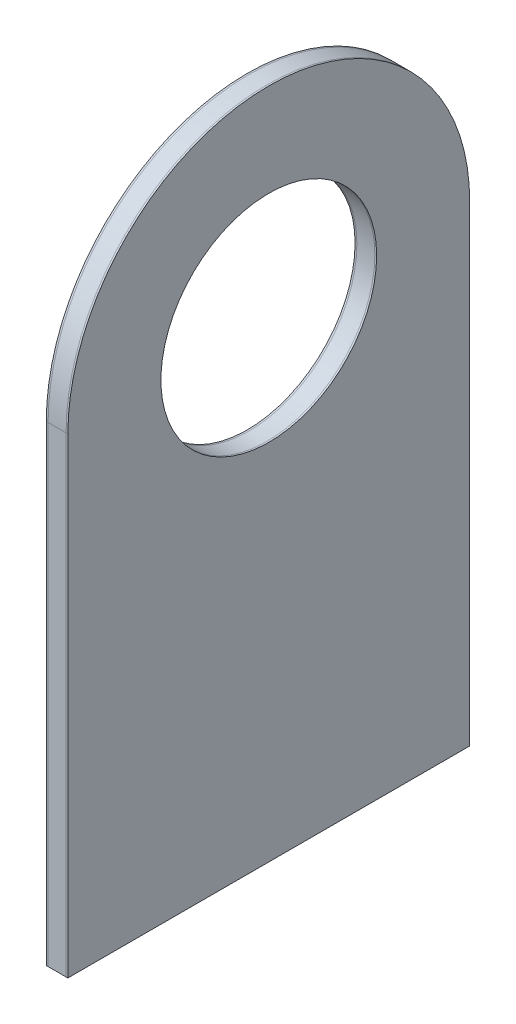
from build123d import *

# Parameters (mm, degrees)
SKETCH1_R           = 15
BOSS_EXTRUDE1_DEPTH = 0.25
SKETCH2_R           = 15
BOSS_EXTRUDE2_DEPTH = 2.5
SKETCH3_R           = 15
BOSS_EXTRUDE3_DEPTH = 0.25


with BuildPart() as part:
    # Sketch1 → Boss-Extrude1 (new body)
    with BuildSketch(Plane(origin=(0, 0, 0), x_dir=(0, 0, -1), z_dir=(1, 0, 0))):
        with BuildLine():
            Line((-27.94, 65.532), (-27.94, 0))
            Line((-27.94, 0), (27.94, 0))
            Line((27.94, 0), (27.94, 65.532))
            ThreePointArc((27.94, 65.532), (0, 93.472), (-27.94, 65.532))
        make_face()
        with Locations((0, 65.532)):
            Circle(SKETCH1_R, mode=Mode.SUBTRACT)
    extrude(amount=BOSS_EXTRUDE1_DEPTH)


with BuildPart() as body_2:
    # Sketch2 → Boss-Extrude2 (new body)
    with BuildSketch(Plane(origin=(0.25, 0, 0), x_dir=(0, 0, -1), z_dir=(1, 0, 0))):
        with BuildLine():
            Line((27.94, 0), (27.94, 65.532))
            ThreePointArc((27.94, 65.532), (0, 93.472), (-27.94, 65.532))
            Line((-27.94, 65.532), (-27.94, 0))
            Line((-27.94, 0), (27.94, 0))
        make_face()
        with Locations((0, 65.532)):
            Circle(SKETCH2_R, mode=Mode.SUBTRACT)
    extrude(amount=BOSS_EXTRUDE2_DEPTH)


with BuildPart() as body_3:
    # Sketch3 → Boss-Extrude3 (new body)
    with BuildSketch(Plane(origin=(2.75, 0, 0), x_dir=(0, 0, -1), z_dir=(1, 0, 0))):
        with BuildLine():
            Line((-27.94, 0), (27.94, 0))
            Line((27.94, 0), (27.94, 65.532))
            ThreePointArc((27.94, 65.532), (0, 93.472), (-27.94, 65.532))
            Line((-27.94, 65.532), (-27.94, 0))
        make_face()
        with Locations((0, 65.532)):
            Circle(SKETCH3_R, mode=Mode.SUBTRACT)
    extrude(amount=BOSS_EXTRUDE3_DEPTH)


solid = Compound([part.part, body_2.part, body_3.part])
